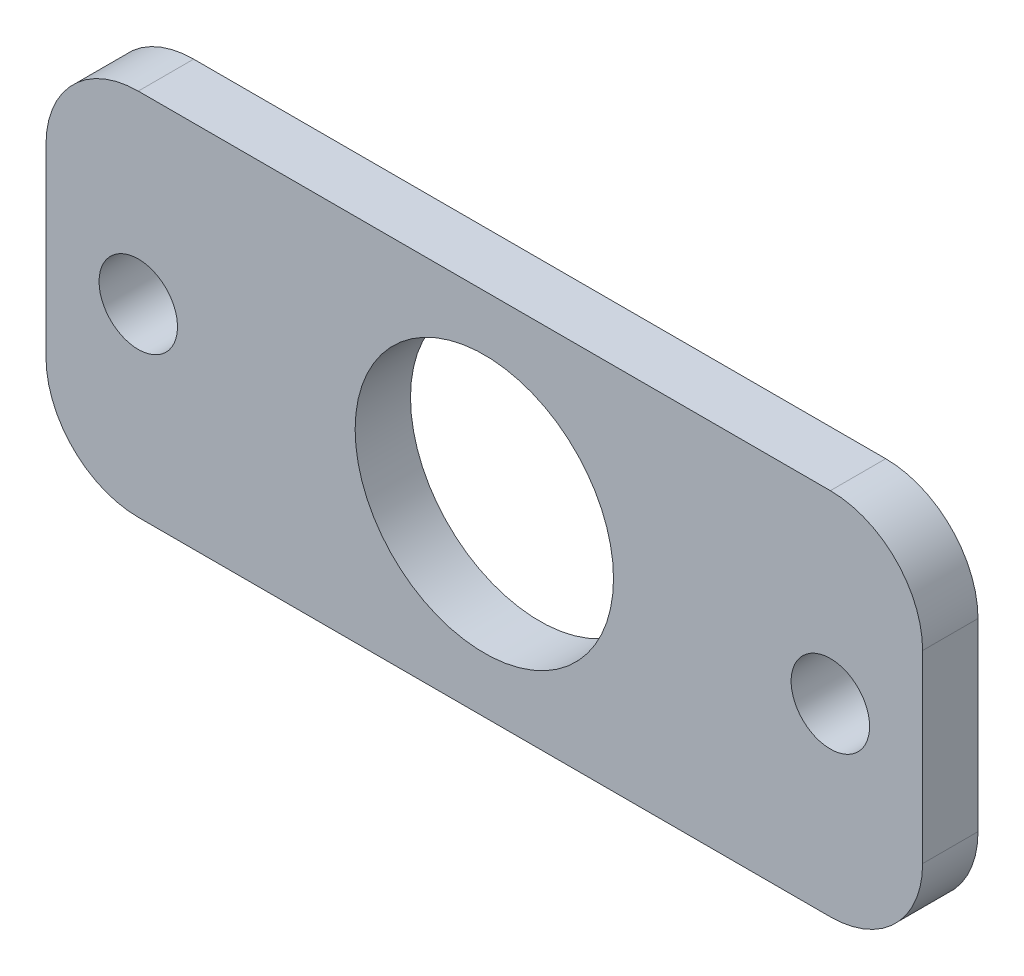
from build123d import *

# Parameters (mm, degrees)
SKETCH1_W           = 95
SKETCH1_H           = 40
SKETCH1_R           = 14
SKETCH1_R_2         = 4.25
BOSS_EXTRUDE1_DEPTH = 6
FILLET1_R           = 10


with BuildPart() as part:
    # Sketch1 → Boss-Extrude1 (new body)
    with BuildSketch(Plane.XY):
        with Locations((347.5, -20)):
            Rectangle(SKETCH1_W, SKETCH1_H)
        with Locations((347.5, -20)):
            Circle(SKETCH1_R, mode=Mode.SUBTRACT)
        with Locations((385, -20)):
            Circle(SKETCH1_R_2, mode=Mode.SUBTRACT)
        with Locations((310, -20)):
            Circle(SKETCH1_R_2, mode=Mode.SUBTRACT)
    extrude(amount=BOSS_EXTRUDE1_DEPTH)

    # Fillet1
    fillet1_edges = [part.edges().sort_by_distance(p)[0] for p in [
        (395, -40, 3),
        (300, -40, 3),
        (300, 0, 3),
        (395, 0, 3),
    ]]
    fillet(fillet1_edges, radius=FILLET1_R)


solid = part.part
